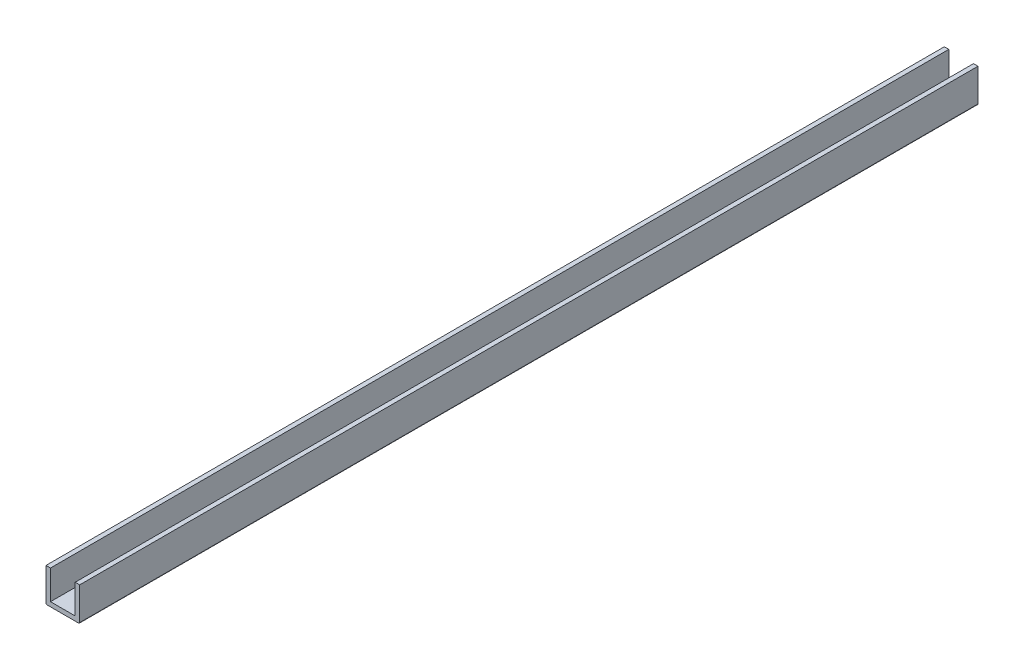
from build123d import *

# Parameters (mm, degrees)
SALIENTE_EXTRUIR1_DEPTH = 400
REDONDEO1_R             = 0.5
CROQUIS2_R              = 2
CROQUIS2_R_2            = 1.75
CORTAR_EXTRUIR1_DEPTH   = 16


with BuildPart() as part:
    # Croquis1 → Saliente-Extruir1 (new body)
    with BuildSketch(Plane.XY):
        Polygon((-7.5, 15), (-7.5, 0), (7.5, 0), (7.5, 15), (5.5, 15), (5.5, 2), (-5.5, 2), (-5.5, 15), align=None)
    extrude(amount=SALIENTE_EXTRUIR1_DEPTH)

    # Redondeo1
    redondeo1_edges = [part.edges().sort_by_distance(p)[0] for p in [
        (7.5, 0, 200),
        (-7.5, 0, 200),
    ]]
    fillet(redondeo1_edges, radius=REDONDEO1_R)

    # Croquis2 → Cortar-Extruir1 (cut, through all)
    with BuildSketch(Plane.XZ):
        with Locations((0, 280)):
            Circle(CROQUIS2_R)
        with Locations((0, 330)):
            Circle(CROQUIS2_R)
        with Locations((0, 390)):
            Circle(CROQUIS2_R_2)
        with Locations((0, 380)):
            Circle(CROQUIS2_R_2)
        with Locations((0, 10)):
            Circle(CROQUIS2_R_2)
        with Locations((0, 20)):
            Circle(CROQUIS2_R_2)
        with Locations((0, 230)):
            Circle(CROQUIS2_R)
        with Locations((0, 180)):
            Circle(CROQUIS2_R)
        with Locations((0, 130)):
            Circle(CROQUIS2_R)
        with Locations((0, 80)):
            Circle(CROQUIS2_R)
        with Locations((0, 30)):
            Circle(CROQUIS2_R)
    extrude(amount=-CORTAR_EXTRUIR1_DEPTH, mode=Mode.SUBTRACT)


solid = part.part
